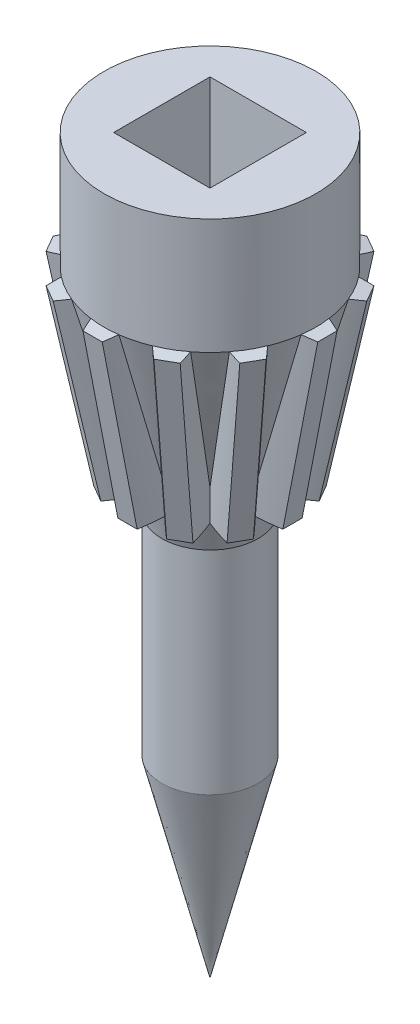
from build123d import *

# Parameters (mm, degrees)
SKETCH2_W           = 10
SKETCH2_H           = 10
CUT_EXTRUDE1_DEPTH  = 14
BOSS_EXTRUDE1_DEPTH = 19
CIRPATTERN1_COUNT   = 12


with BuildPart() as part:
    # Sketch1 → Revolve1 (revolve)
    with BuildSketch(Plane.XY):
        Polygon((11, 44), (5, 22), (5, 0), (0, -20), (0, 56), (11, 56), align=None)
    revolve(axis=Axis((0, 56, 0), (0, -1, 0)))

    # Sketch2 → Cut-Extrude1 (cut)
    with BuildSketch(Plane(origin=(0, 56, 0), x_dir=(1, 0, 0), z_dir=(0, 1, 0))):
        Rectangle(SKETCH2_W, SKETCH2_H)
    extrude(amount=-CUT_EXTRUDE1_DEPTH, mode=Mode.SUBTRACT)

    # Sketch4 → Boss-Extrude1 (add)
    with BuildSketch(Plane(origin=(-8.641833855, 44.458381064, 0), x_dir=(-0.981627183, -0.190808995, 0), z_dir=(0.190808995, -0.981627183, 0))):
        with BuildLine():
            Line((3.612595277, -1), (3.612595277, 1))
            ThreePointArc((3.612595277, 1), (1.799104611, 1.596675813), (-0.067177541, 1.998871477))
            add(Edge.make_bspline(
                [(-0.067177541, -1.998871477), (0.295411783, 0), (-0.067177541, 1.998871477)],
                knots=[4.529658174, 4.529658174, 4.529658174, 4.895119786, 4.895119786, 4.895119786], degree=2, weights=[1, 0.98335113, 1]))
            ThreePointArc((-0.067177541, -1.998871477), (1.799104611, -1.596675813), (3.612595277, -1))
        make_face()
    boss_extrude1 = extrude(amount=BOSS_EXTRUDE1_DEPTH)

    # CirPattern1: Boss-Extrude1 ×12 about axis
    cirpattern1_axis = Axis((0, 0, 0), (0, 1, 0))
    for i in range(1, CIRPATTERN1_COUNT):
        add(boss_extrude1.rotate(cirpattern1_axis, i * 360 / CIRPATTERN1_COUNT))


solid = part.part
